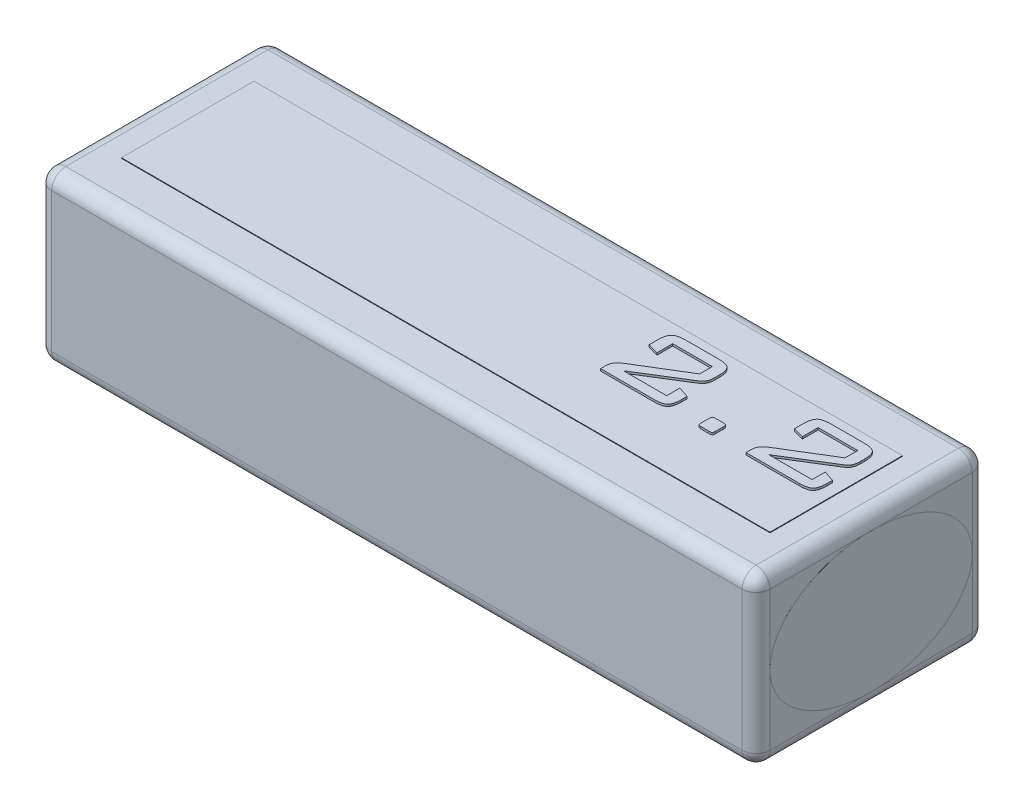
from build123d import *

# Parameters (mm, degrees)
ESBO_O1_W                  = 103
ESBO_O1_H                  = 33
RESSALTO_EXTRUS_O1_DEPTH   = 24
FILETE1_R                  = 2
ESBO_O4_RX                 = 14.5
ESBO_O4_RY                 = 10
RESSALTO_EXTRUS_O3_DEPTH   = 0.001
ESBO_O5_RX                 = 14.508383713
ESBO_O5_RY                 = 10.005781871
RESSALTO_EXTRUS_O4_DEPTH   = 0.001
ESBO_O6_W                  = 93
ESBO_O6_H                  = 19
RESSALTO_EXTRUS_O5_DEPTH   = 0.09
RESSALTO_EXTRUS_O6_DEPTH   = 0.3
RESSALTO_EXTRUS_O6_2_DEPTH = 0.3
RESSALTO_EXTRUS_O6_3_DEPTH = 0.3


with BuildPart() as part:
    # Esboço1 → Ressalto-extrusão1 (new body)
    with BuildSketch(Plane(origin=(0, 0, 0), x_dir=(1, 0, 0), z_dir=(0, 1, 0))):
        with Locations((-49.434832339, -22.419016433)):
            Rectangle(ESBO_O1_W, ESBO_O1_H)
    extrude(amount=RESSALTO_EXTRUS_O1_DEPTH)

    # Filete1
    filete1_edges = [part.edges().sort_by_distance(p)[0] for p in [
        (2.065167661, 24, 22.419016433),
        (-49.434832339, 24, 5.919016433),
        (-100.934832339, 24, 22.419016433),
        (-49.434832339, 0, 5.919016433),
        (2.065167661, 0, 22.419016433),
        (-49.434832339, 0, 38.919016433),
        (-100.934832339, 0, 22.419016433),
        (-49.434832339, 24, 38.919016433),
        (-100.934832339, 12, 5.919016433),
        (2.065167661, 12, 5.919016433),
        (2.065167661, 12, 38.919016433),
        (-100.934832339, 12, 38.919016433),
    ]]
    fillet(filete1_edges, radius=FILETE1_R)


with BuildPart() as body_2:
    # Esboço4 → Ressalto-extrusão3 (new body)
    with BuildSketch(Plane(origin=(2.065167661, 0, 0), x_dir=(0, 0, -1), z_dir=(1, 0, 0))):
        with Locations((-22.419016433, 12)):
            Ellipse(ESBO_O4_RX, ESBO_O4_RY)
    extrude(amount=RESSALTO_EXTRUS_O3_DEPTH)


with BuildPart() as body_3:
    # Esboço5 → Ressalto-extrusão4 (new body)
    with BuildSketch(Plane.ZY.offset(100.934832339)):
        with Locations(Location((22.419016433, 12), (0, 0, 178.052097389))):
            Ellipse(ESBO_O5_RX, ESBO_O5_RY)
    extrude(amount=RESSALTO_EXTRUS_O4_DEPTH)


with BuildPart() as body_4:
    # Esboço6 → Ressalto-extrusão5 (new body)
    with BuildSketch(Plane(origin=(0, 24, 0), x_dir=(1, 0, 0), z_dir=(0, 1, 0))):
        with Locations((-49.434832339, -22.419016433)):
            Rectangle(ESBO_O6_W, ESBO_O6_H)
    extrude(amount=RESSALTO_EXTRUS_O5_DEPTH)


with BuildPart() as body_5:
    # Esboço7 → Ressalto-extrusão6 (new body)
    with BuildSketch(Plane(origin=(0, 24.09, 0), x_dir=(1, 0, 0), z_dir=(0, 1, 0))):
        with BuildLine():
            add(Edge.make_bspline(
                [(-34.569489175, -16.382666091), (-34.569159217, -16.29195482), (-34.568527629, -16.118319912), (-34.544365709, -15.86874775), (-34.515567084, -15.640345677), (-34.466072737, -15.435428235), (-34.406847229, -15.252257331), (-34.336359257, -15.089356146), (-34.245765536, -14.951314355), (-34.143989878, -14.83123272), (-34.022466134, -14.728065826), (-33.87302629, -14.645915671), (-33.700796519, -14.573354334), (-33.502915273, -14.515045774), (-33.281336733, -14.469616048), (-33.034657833, -14.439018811), (-32.762530046, -14.415737968), (-32.571897747, -14.41501136), (-32.472226548, -14.414631456)],
                knots=[0, 0, 0, 0, 0.000271971, 0.000520592, 0.000751703, 0.000961974, 0.00115183, 0.001328967, 0.001492509, 0.001645233, 0.001800008, 0.001967643, 0.002154652, 0.002359918, 0.002585377, 0.002832492, 0.003105261, 0.003404149, 0.003404149, 0.003404149, 0.003404149], degree=3))
            Line((-32.472226548, -14.414631456), (-27.817326569, -14.414631456))
            add(Edge.make_bspline(
                [(-27.817326569, -14.414631456), (-27.721240632, -14.415010804), (-27.536873435, -14.415738687), (-27.272865163, -14.439256483), (-27.033200791, -14.469156203), (-26.81814253, -14.515584003), (-26.626855111, -14.572482852), (-26.461007909, -14.647250322), (-26.315334189, -14.727961011), (-26.196594694, -14.831365734), (-26.097656485, -14.951485252), (-26.009527359, -15.089507646), (-25.942728474, -15.252931921), (-25.88171909, -15.434956711), (-25.836992145, -15.64081293), (-25.80677609, -15.868667519), (-25.783042451, -16.118342848), (-25.78234832, -16.291962691), (-25.781985688, -16.382666091)],
                knots=[0, 0, 0, 0, 0.000288121, 0.000552839, 0.000794618, 0.001012174, 0.00121229, 0.001391885, 0.00155719, 0.001709915, 0.001860897, 0.002022992, 0.002199041, 0.002388897, 0.002598565, 0.002829675, 0.003078297, 0.003350267, 0.003350267, 0.003350267, 0.003350267], degree=3))
            Line((-25.781985688, -16.382666091), (-25.781985688, -16.980345556))
            add(Edge.make_bspline(
                [(-25.781985688, -16.980345556), (-25.785312469, -17.089031986), (-25.791583018, -17.293891707), (-25.831816496, -17.584641476), (-25.910414719, -17.835289496), (-26.018062275, -18.061449596), (-26.18781418, -18.262360333), (-26.413625817, -18.465763433), (-26.708129534, -18.675430315), (-26.932305041, -18.809210124), (-27.052727614, -18.881073946)],
                knots=[0, 0, 0, 0, 0.000326162, 0.000614774, 0.000877044, 0.001111826, 0.001360739, 0.001659918, 0.002022343, 0.002442998, 0.002442998, 0.002442998, 0.002442998], degree=3))
            Line((-27.052727614, -18.881073946), (-33.185672756, -22.685222974))
            Line((-33.185672756, -22.685222974), (-26.988113617, -22.685222974))
            Line((-26.988113617, -22.685222974), (-26.988113617, -20.789879084))
            Line((-26.988113617, -20.789879084), (-25.437377708, -21.309483304))
            Line((-25.437377708, -21.309483304), (-25.437377708, -22.101004758))
            add(Edge.make_bspline(
                [(-25.437377708, -22.101004758), (-25.438133978, -22.191671358), (-25.439580983, -22.365147836), (-25.458076763, -22.614345869), (-25.491125128, -22.840612779), (-25.531287256, -23.047158565), (-25.592344954, -23.228731214), (-25.657363658, -23.391961353), (-25.742427254, -23.529088862), (-25.837364026, -23.649910673), (-25.955883965, -23.748656305), (-26.092869914, -23.835259025), (-26.255451379, -23.90415107), (-26.438994922, -23.963670952), (-26.647399937, -24.008673372), (-26.879733316, -24.039189134), (-27.134829877, -24.062451849), (-27.312918804, -24.063243655), (-27.405412343, -24.063654893)],
                knots=[0, 0, 0, 0, 0.000271971, 0.000520373, 0.000748818, 0.000957915, 0.00115033, 0.001322845, 0.001483525, 0.001632793, 0.001781721, 0.001943816, 0.002117398, 0.002309814, 0.002522109, 0.002755886, 0.003012555, 0.003289909, 0.003289909, 0.003289909, 0.003289909], degree=3))
            Line((-27.405412343, -24.063654893), (-35.086401145, -24.063654893))
            Line((-35.086401145, -24.063654893), (-35.086401145, -23.43636068))
            add(Edge.make_bspline(
                [(-35.086401145, -23.43636068), (-35.084250484, -23.327481698), (-35.080184881, -23.121657305), (-35.025294355, -22.834416933), (-34.941515987, -22.585806648), (-34.813592283, -22.373817878), (-34.641799183, -22.185508418), (-34.430278922, -21.999151722), (-34.176774442, -21.803979876), (-33.986346445, -21.683039312), (-33.885657715, -21.619092036)],
                knots=[0, 0, 0, 0, 0.000326162, 0.000616576, 0.000873739, 0.001109215, 0.001353365, 0.001635525, 0.001954304, 0.002311978, 0.002311978, 0.002311978, 0.002311978], degree=3))
            Line((-33.885657715, -21.619092036), (-27.332721597, -17.621101019))
            Line((-27.332721597, -17.621101019), (-27.332721597, -15.793063376))
            Line((-27.332721597, -15.793063376), (-33.018753266, -15.793063376))
            Line((-33.018753266, -15.793063376), (-33.018753266, -18.033015245))
            Line((-33.018753266, -18.033015245), (-34.569489175, -17.623793269))
            Line((-34.569489175, -17.623793269), (-34.569489175, -16.382666091))
        make_face()
    extrude(amount=RESSALTO_EXTRUS_O6_DEPTH)


with BuildPart() as body_6:
    # Esboço7 → Ressalto-extrus_o6 2 (new body)
    with BuildSketch(Plane(origin=(0, 24.09, 0), x_dir=(1, 0, 0), z_dir=(0, 1, 0))):
        with BuildLine():
            add(Edge.make_bspline(
                [(-19.630194796, -21.996007014), (-19.570880606, -21.996441733), (-19.464434134, -21.997221888), (-19.324398168, -22.015678332), (-19.220110317, -22.04121003), (-19.146778848, -22.087920251), (-19.108163548, -22.160750834), (-19.078464587, -22.250358029), (-19.064841828, -22.368101861), (-19.06309217, -22.454591549), (-19.062130079, -22.502149985)],
                knots=[0, 0, 0, 0, 0.00017777, 0.00031903, 0.000422952, 0.000498383, 0.000570874, 0.000664524, 0.000781413, 0.000924203, 0.000924203, 0.000924203, 0.000924203], degree=3))
            Line((-19.062130079, -22.502149985), (-19.062130079, -23.576357672))
            add(Edge.make_bspline(
                [(-19.062130079, -23.576357672), (-19.063231582, -23.623920888), (-19.065211511, -23.709414861), (-19.076945407, -23.824717444), (-19.099847531, -23.912315933), (-19.135408861, -23.982680074), (-19.209563609, -24.023959434), (-19.313801902, -24.046303761), (-19.458385886, -24.061765061), (-19.568230268, -24.062973307), (-19.630194796, -24.063654893)],
                knots=[0, 0, 0, 0, 0.000142791, 0.000256664, 0.000346158, 0.000414956, 0.000485161, 0.00059095, 0.00073455, 0.000920394, 0.000920394, 0.000920394, 0.000920394], degree=3))
            Line((-19.630194796, -24.063654893), (-20.755555231, -24.063654893))
            add(Edge.make_bspline(
                [(-20.755555231, -24.063654893), (-20.78881555, -24.062758805), (-20.850418408, -24.061099121), (-20.934566012, -24.046057373), (-21.001884681, -24.019103669), (-21.057076508, -23.97893753), (-21.092356623, -23.912699523), (-21.114849168, -23.824570463), (-21.126736957, -23.709467234), (-21.128690909, -23.623939609), (-21.129777959, -23.576357672)],
                knots=[0, 0, 0, 0, 9.9759e-05, 0.000184767, 0.000254766, 0.000316159, 0.000384956, 0.00047445, 0.000588323, 0.000731114, 0.000731114, 0.000731114, 0.000731114], degree=3))
            Line((-21.129777959, -23.576357672), (-21.129777959, -22.502149985))
            add(Edge.make_bspline(
                [(-21.129777959, -22.502149985), (-21.128952764, -22.454552051), (-21.127452066, -22.367990534), (-21.112354892, -22.25095318), (-21.086905629, -22.160405733), (-21.047497398, -22.086971602), (-20.972104889, -22.042093919), (-20.867683306, -22.015384182), (-20.727410426, -21.997329548), (-20.621004718, -21.996480257), (-20.561713242, -21.996007014)],
                knots=[0, 0, 0, 0, 0.000142791, 0.000259679, 0.000352513, 0.000425004, 0.00050266, 0.000606583, 0.000747842, 0.000925612, 0.000925612, 0.000925612, 0.000925612], degree=3))
            Line((-20.561713242, -21.996007014), (-19.630194796, -21.996007014))
        make_face()
    extrude(amount=RESSALTO_EXTRUS_O6_2_DEPTH)


with BuildPart() as body_7:
    # Esboço7 → Ressalto-extrus_o6 3 (new body)
    with BuildSketch(Plane(origin=(0, 24.09, 0), x_dir=(1, 0, 0), z_dir=(0, 1, 0))):
        with BuildLine():
            add(Edge.make_bspline(
                [(-13.720706391, -16.382666091), (-13.720376433, -16.29195482), (-13.719744844, -16.118319912), (-13.695582925, -15.86874775), (-13.6667843, -15.640345677), (-13.617289953, -15.435428235), (-13.558064444, -15.252257331), (-13.487576472, -15.089356146), (-13.396982751, -14.951314355), (-13.295207094, -14.83123272), (-13.17368335, -14.728065826), (-13.024243506, -14.645915671), (-12.852013735, -14.573354334), (-12.654132489, -14.515045774), (-12.432553949, -14.469616048), (-12.185875048, -14.439018811), (-11.913747262, -14.415737968), (-11.723114963, -14.41501136), (-11.623443763, -14.414631456)],
                knots=[0, 0, 0, 0, 0.000271971, 0.000520592, 0.000751703, 0.000961974, 0.00115183, 0.001328967, 0.001492509, 0.001645233, 0.001800008, 0.001967643, 0.002154652, 0.002359918, 0.002585377, 0.002832492, 0.003105261, 0.003404149, 0.003404149, 0.003404149, 0.003404149], degree=3))
            Line((-11.623443763, -14.414631456), (-6.968543784, -14.414631456))
            add(Edge.make_bspline(
                [(-6.968543784, -14.414631456), (-6.872457847, -14.415010804), (-6.688090651, -14.415738687), (-6.424082379, -14.439256483), (-6.184418006, -14.469156203), (-5.969359745, -14.515584003), (-5.778072327, -14.572482852), (-5.612225124, -14.647250322), (-5.466551404, -14.727961011), (-5.34781191, -14.831365734), (-5.248873701, -14.951485252), (-5.160744574, -15.089507646), (-5.093945689, -15.252931921), (-5.032936305, -15.434956711), (-4.988209361, -15.64081293), (-4.957993306, -15.868667519), (-4.934259666, -16.118342848), (-4.933565535, -16.291962691), (-4.933202903, -16.382666091)],
                knots=[0, 0, 0, 0, 0.000288121, 0.000552839, 0.000794618, 0.001012174, 0.00121229, 0.001391885, 0.00155719, 0.001709915, 0.001860897, 0.002022992, 0.002199041, 0.002388897, 0.002598565, 0.002829675, 0.003078297, 0.003350267, 0.003350267, 0.003350267, 0.003350267], degree=3))
            Line((-4.933202903, -16.382666091), (-4.933202903, -16.980345556))
            add(Edge.make_bspline(
                [(-4.933202903, -16.980345556), (-4.936529685, -17.089031986), (-4.942800234, -17.293891707), (-4.983033711, -17.584641476), (-5.061631934, -17.835289496), (-5.16927949, -18.061449596), (-5.339031395, -18.262360333), (-5.564843033, -18.465763433), (-5.85934675, -18.675430315), (-6.083522256, -18.809210124), (-6.203944829, -18.881073946)],
                knots=[0, 0, 0, 0, 0.000326162, 0.000614774, 0.000877044, 0.001111826, 0.001360739, 0.001659918, 0.002022343, 0.002442998, 0.002442998, 0.002442998, 0.002442998], degree=3))
            Line((-6.203944829, -18.881073946), (-12.336889971, -22.685222974))
            Line((-12.336889971, -22.685222974), (-6.139330833, -22.685222974))
            Line((-6.139330833, -22.685222974), (-6.139330833, -20.789879084))
            Line((-6.139330833, -20.789879084), (-4.588594923, -21.309483304))
            Line((-4.588594923, -21.309483304), (-4.588594923, -22.101004758))
            add(Edge.make_bspline(
                [(-4.588594923, -22.101004758), (-4.589351193, -22.191671358), (-4.590798198, -22.365147836), (-4.609293978, -22.614345869), (-4.642342343, -22.840612779), (-4.682504472, -23.047158565), (-4.74356217, -23.228731214), (-4.808580874, -23.391961353), (-4.893644469, -23.529088862), (-4.988581241, -23.649910673), (-5.107101181, -23.748656305), (-5.24408713, -23.835259025), (-5.406668595, -23.90415107), (-5.590212137, -23.963670952), (-5.798617152, -24.008673372), (-6.030950531, -24.039189134), (-6.286047093, -24.062451849), (-6.46413602, -24.063243655), (-6.556629558, -24.063654893)],
                knots=[0, 0, 0, 0, 0.000271971, 0.000520373, 0.000748818, 0.000957915, 0.00115033, 0.001322845, 0.001483525, 0.001632793, 0.001781721, 0.001943816, 0.002117398, 0.002309814, 0.002522109, 0.002755886, 0.003012555, 0.003289909, 0.003289909, 0.003289909, 0.003289909], degree=3))
            Line((-6.556629558, -24.063654893), (-14.237618361, -24.063654893))
            Line((-14.237618361, -24.063654893), (-14.237618361, -23.43636068))
            add(Edge.make_bspline(
                [(-14.237618361, -23.43636068), (-14.235467699, -23.327481698), (-14.231402097, -23.121657305), (-14.17651157, -22.834416933), (-14.092733203, -22.585806648), (-13.964809498, -22.373817878), (-13.793016398, -22.185508418), (-13.581496137, -21.999151722), (-13.327991658, -21.803979876), (-13.137563661, -21.683039312), (-13.036874931, -21.619092036)],
                knots=[0, 0, 0, 0, 0.000326162, 0.000616576, 0.000873739, 0.001109215, 0.001353365, 0.001635525, 0.001954304, 0.002311978, 0.002311978, 0.002311978, 0.002311978], degree=3))
            Line((-13.036874931, -21.619092036), (-6.483938813, -17.621101019))
            Line((-6.483938813, -17.621101019), (-6.483938813, -15.793063376))
            Line((-6.483938813, -15.793063376), (-12.169970481, -15.793063376))
            Line((-12.169970481, -15.793063376), (-12.169970481, -18.033015245))
            Line((-12.169970481, -18.033015245), (-13.720706391, -17.623793269))
            Line((-13.720706391, -17.623793269), (-13.720706391, -16.382666091))
        make_face()
    extrude(amount=RESSALTO_EXTRUS_O6_3_DEPTH)


solid = Compound([part.part, body_2.part, body_3.part, body_4.part, body_5.part, body_6.part, body_7.part])
